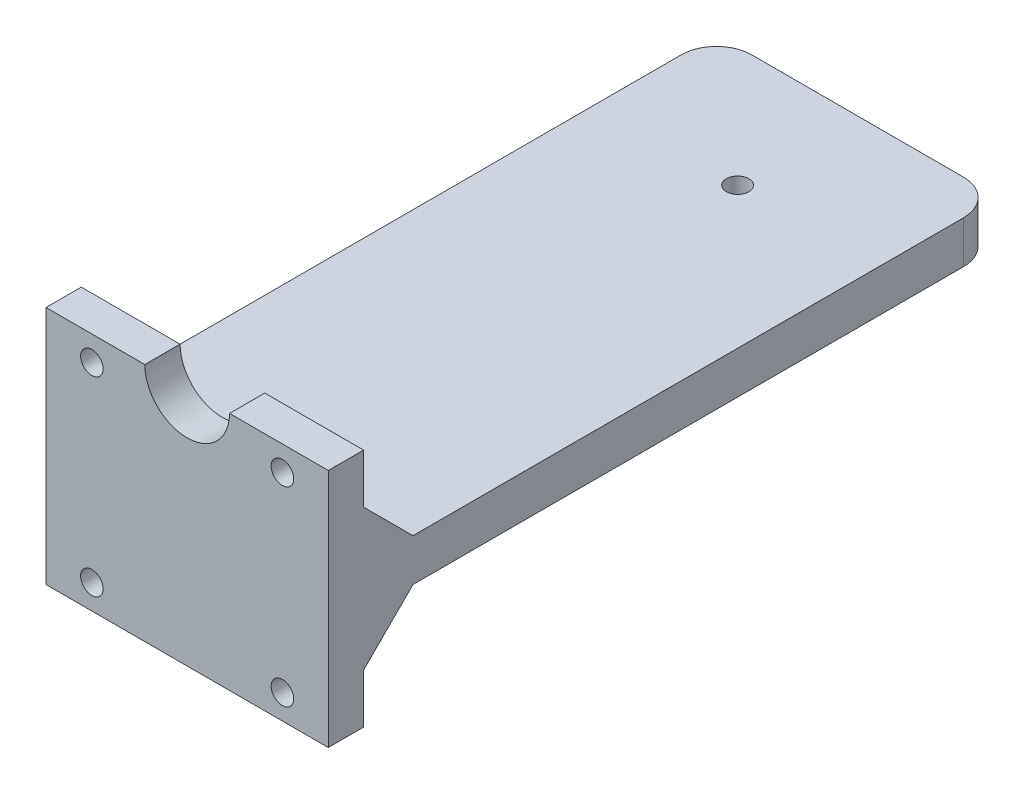
from build123d import *

# Parameters (mm, degrees)
SKETCH_1_W          = 40
SKETCH_1_H          = 95
EXTRUDE_1_DEPTH     = 6
SKETCH_2_W          = 40
SKETCH_2_H          = 5
EXTRUDE_2_DEPTH     = 14
SKETCH_3_R          = 6
CUT_EXTRUDE_1_DEPTH = 14
SKETCH_4_R          = 1.6
CUT_EXTRUDE_2_DEPTH = 14
CHAMFER_1_SIZE      = 7
FILLET_1_R          = 5
EXTRUDE_3_DEPTH     = 40
SKETCH_8_R          = 1.6
CUT_EXTRUDE_3_DEPTH = 40
SKETCH_5_R          = 7
EXTRUDE_4_DEPTH     = 2
SKETCH_9_R          = 6.05
EXTRUDE_5_DEPTH     = 4
CHAMFER_2_SIZE      = 0.5
SKETCH_10_R         = 1.6
CUT_EXTRUDE_4_DEPTH = 27


with BuildPart() as part:
    # Эскиз1 → Бобышка-Вытянуть1 (new body)
    with BuildSketch(Plane(origin=(0, 0, 0), x_dir=(1, 0, 0), z_dir=(0, 1, 0))):
        with Locations((0, 47.5)):
            Rectangle(SKETCH_1_W, SKETCH_1_H)
    extrude(amount=EXTRUDE_1_DEPTH)

    # Эскиз2 → Бобышка-Вытянуть2 (add)
    with BuildSketch(Plane(origin=(0, 6, 0), x_dir=(1, 0, 0), z_dir=(0, 1, 0))):
        with Locations((0, 2.5)):
            Rectangle(SKETCH_2_W, SKETCH_2_H)
    extrude(amount=EXTRUDE_2_DEPTH)

    # Эскиз3 → Вырез-Вытянуть1 (cut)
    with BuildSketch(Plane(origin=(0, 0, -5), x_dir=(-1, 0, 0), z_dir=(0, 0, -1))):
        with Locations((0, 20)):
            Circle(SKETCH_3_R)
    extrude(amount=-CUT_EXTRUDE_1_DEPTH, mode=Mode.SUBTRACT)

    # Эскиз4 → Вырез-Вытянуть2 (cut)
    with BuildSketch(Plane(origin=(0, 0, -5), x_dir=(-1, 0, 0), z_dir=(0, 0, -1))):
        with Locations((-13.5, 16.5)):
            Circle(SKETCH_4_R)
        with Locations((13.5, 16.5)):
            Circle(SKETCH_4_R)
    extrude(amount=-CUT_EXTRUDE_2_DEPTH, mode=Mode.SUBTRACT)

    # Фаска1
    chamfer_1_edges = [part.edges().sort_by_distance(p)[0] for p in [
        (0, 6, -5),
    ]]
    chamfer(chamfer_1_edges, length=CHAMFER_1_SIZE)

    # Скругление1
    fillet_1_edges = [part.edges().sort_by_distance(p)[0] for p in [
        (-20, 3, -95),
        (20, 3, -95),
    ]]
    fillet(fillet_1_edges, radius=FILLET_1_R)

    # Эскиз7 → Бобышка-Вытянуть3 (add)
    with BuildSketch(Plane.ZY.offset(20)):
        Polygon((0, -14), (-5, -14), (-5, -7), (-12, 0), (0, 0), align=None)
    extrude(amount=-EXTRUDE_3_DEPTH)

    # Эскиз8 → Вырез-Вытянуть3 (cut)
    with BuildSketch(Plane.XY):
        with Locations((13.5, 16.5)):
            Circle(SKETCH_8_R)
        with Locations((-13.5, 16.5)):
            Circle(SKETCH_8_R)
        with Locations((13.5, -10.5)):
            Circle(SKETCH_8_R)
        with Locations((-13.5, -10.5)):
            Circle(SKETCH_8_R)
    extrude(amount=-CUT_EXTRUDE_3_DEPTH, mode=Mode.SUBTRACT)

    # Эскиз5 → Бобышка-Вытянуть4 (add)
    with BuildSketch(Plane.XZ):
        with Locations((0, -78)):
            Circle(SKETCH_5_R)
    extrude(amount=EXTRUDE_4_DEPTH)

    # Эскиз9 → Бобышка-Вытянуть5 (add)
    with BuildSketch(Plane.XZ.offset(2)):
        with Locations((0, -78)):
            Circle(SKETCH_9_R)
    extrude(amount=EXTRUDE_5_DEPTH)

    # Фаска2
    chamfer_2_edges = [part.edges().sort_by_distance(p)[0] for p in [
        (-6.05, -6, -78),
    ]]
    chamfer(chamfer_2_edges, length=CHAMFER_2_SIZE)

    # Эскиз10 → Вырез-Вытянуть4 (cut, through all)
    with BuildSketch(Plane.XZ.offset(6)):
        with Locations((0, -78)):
            Circle(SKETCH_10_R)
    extrude(amount=-CUT_EXTRUDE_4_DEPTH, mode=Mode.SUBTRACT)


solid = part.part
